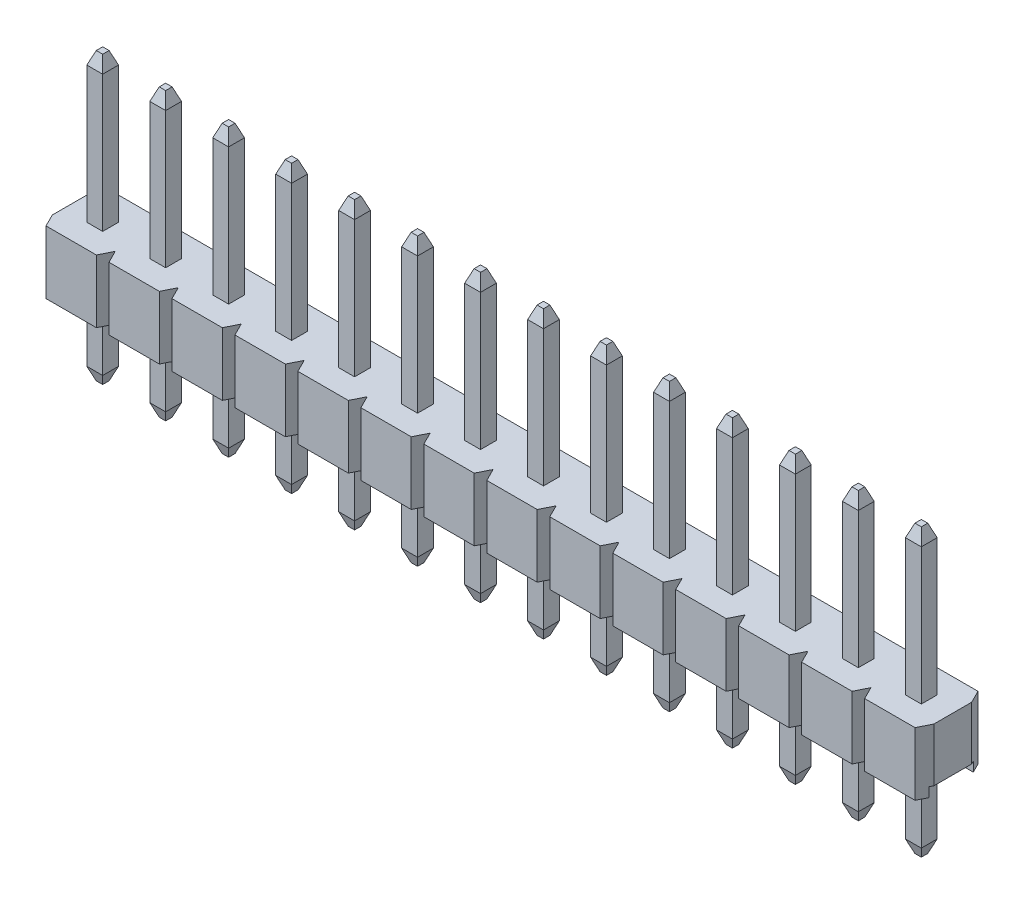
from build123d import *
from OCP.BRepFilletAPI import BRepFilletAPI_MakeChamfer

# Parameters (mm, degrees)
SKETCH1_W                     = 2.54
SKETCH1_H                     = 2.54
MAIN_BODY_DEPTH               = 2.54
SKETCH3_W                     = 1.778
SKETCH3_H                     = 0.381
CUT_EXTRUDE1_DEPTH            = 5.399409051
CUT_EXTRUDE2_DEPTH            = 5.399409051
BODY_PATTERN_COUNT            = 14
BODY_PATTERN_PITCH            = 2.54
PIN_START                     = -5.54
SKETCH2_W                     = 0.64
SKETCH2_H                     = 0.64
PIN_DEPTH                     = 11.54
CHAMFER1_SIZE                 = 0.508
CHAMFER1_SIZE2                = 0.1905
CHAMFER2_SIZE                 = 0.1905
CHAMFER2_SIZE2                = 0.508
PIN_PATTERN_COUNT             = 14
PIN_PATTERN_PITCH             = 2.54
CHAMFER1_OF_PIN_PATTERN_SIZE  = 0.508
CHAMFER1_OF_PIN_PATTERN_SIZE2 = 0.1905
CHAMFER2_OF_PIN_PATTERN_SIZE2 = 0.1905
CHAMFER2_OF_PIN_PATTERN_SIZE  = 0.508


with BuildPart() as part:
    # Sketch1 → Main Body (new body)
    with BuildSketch(Plane(origin=(0, 0, 0), x_dir=(1, 0, 0), z_dir=(0, 1, 0))):
        with Locations((1.27, 1.27)):
            Rectangle(SKETCH1_W, SKETCH1_H)
    main_body = extrude(amount=MAIN_BODY_DEPTH)

    # Sketch3 → Cut-Extrude1 (cut, through all)
    with BuildSketch(Plane.ZY):
        with Locations((-1.27, 0.1905)):
            Rectangle(SKETCH3_W, SKETCH3_H)
    cut_extrude1 = extrude(amount=-CUT_EXTRUDE1_DEPTH, mode=Mode.SUBTRACT)

    # Sketch4 → Cut-Extrude2 (cut, through all)
    with BuildSketch(Plane(origin=(0, 2.54, 0), x_dir=(1, 0, 0), z_dir=(0, 1, 0))):
        Polygon((0.254, 2.54), (0, 2.54), (0, 2.032), align=None)
        Polygon((2.54, 2.54), (2.286, 2.54), (2.54, 2.032), align=None)
        Polygon((0.254, 0), (0, 0.508), (0, 0), align=None)
        Polygon((2.54, 0), (2.286, 0), (2.54, 0.508), align=None)
    cut_extrude2 = extrude(amount=-CUT_EXTRUDE2_DEPTH, mode=Mode.SUBTRACT)

    # Body Pattern: Main Body, Cut-Extrude1, Cut-Extrude2 ×14
    with Locations(*[(-i * BODY_PATTERN_PITCH, 0, 0) for i in range(1, BODY_PATTERN_COUNT)]):
        add(main_body)
        add(cut_extrude1, mode=Mode.SUBTRACT)
        add(cut_extrude2, mode=Mode.SUBTRACT)

    # Sketch2 → Pin (add)
    with BuildSketch(Plane(origin=(0, 2.54, 0), x_dir=(1, 0, 0), z_dir=(0, 1, 0)).offset(PIN_START)):
        with Locations((1.27, 1.27)):
            Rectangle(SKETCH2_W, SKETCH2_H)
    pin = extrude(amount=PIN_DEPTH)

    # Chamfer1: one chamfer whose edges measure the first distance from different faces: ONE call of the kernel's chamfer builder (chamfer() names one face for all edges)
    chamfer1_edges_1 = [part.edges().sort_by_distance(p)[0] for p in [
        (0.95, 8.54, -1.27),
    ]]
    chamfer1_side_1 = [part.faces().sort_by_distance(p)[0] for p in [
        (0.95, 5.54, -1.27),
    ]]
    chamfer1_edges_2 = [part.edges().sort_by_distance(p)[0] for p in [
        (1.27, 8.54, -0.95),
    ]]
    chamfer1_side_2 = [part.faces().sort_by_distance(p)[0] for p in [
        (1.27, 5.54, -0.95),
    ]]
    chamfer1_edges_3 = [part.edges().sort_by_distance(p)[0] for p in [
        (1.59, 8.54, -1.27),
    ]]
    chamfer1_side_3 = [part.faces().sort_by_distance(p)[0] for p in [
        (1.59, 5.54, -1.27),
    ]]
    chamfer1_edges_4 = [part.edges().sort_by_distance(p)[0] for p in [
        (1.27, 8.54, -1.59),
    ]]
    chamfer1_side_4 = [part.faces().sort_by_distance(p)[0] for p in [
        (1.27, 5.54, -1.59),
    ]]
    chamfer1 = BRepFilletAPI_MakeChamfer(part.part.solid().wrapped)
    for e in chamfer1_edges_1:
        chamfer1.Add(CHAMFER1_SIZE, CHAMFER1_SIZE2, e.wrapped, chamfer1_side_1[0].wrapped)  # the first distance lies on this face
    for e in chamfer1_edges_2:
        chamfer1.Add(CHAMFER1_SIZE, CHAMFER1_SIZE2, e.wrapped, chamfer1_side_2[0].wrapped)  # the first distance lies on this face
    for e in chamfer1_edges_3:
        chamfer1.Add(CHAMFER1_SIZE, CHAMFER1_SIZE2, e.wrapped, chamfer1_side_3[0].wrapped)  # the first distance lies on this face
    for e in chamfer1_edges_4:
        chamfer1.Add(CHAMFER1_SIZE, CHAMFER1_SIZE2, e.wrapped, chamfer1_side_4[0].wrapped)  # the first distance lies on this face
    add(Compound.cast(chamfer1.Shape()), mode=Mode.REPLACE)

    # Chamfer2
    chamfer2_edges = [part.edges().sort_by_distance(p)[0] for p in [
        (1.27, -3, -0.95),
        (1.59, -3, -1.27),
        (1.27, -3, -1.59),
        (0.95, -3, -1.27),
    ]]
    chamfer2_side = [part.faces().sort_by_distance(p)[0] for p in [
        (1.27, -3, -1.27),
    ]]
    chamfer(chamfer2_edges, length=CHAMFER2_SIZE, length2=CHAMFER2_SIZE2, reference=chamfer2_side[0])

    # Pin Pattern: Pin ×14
    with Locations(*[(-i * PIN_PATTERN_PITCH, 0, 0) for i in range(1, PIN_PATTERN_COUNT)]):
        add(pin)

    # Chamfer1 of Pin Pattern: one chamfer whose edges measure the first distance from different faces: ONE call of the kernel's chamfer builder (chamfer() names one face for all edges)
    chamfer1_of_pin_pattern_edges_1 = [part.edges().sort_by_distance(p)[0] for p in [
        (-1.59, 8.54, -1.27),
    ]]
    chamfer1_of_pin_pattern_side_1 = [part.faces().sort_by_distance(p)[0] for p in [
        (-1.59, 5.54, -1.27),
    ]]
    chamfer1_of_pin_pattern_edges_2 = [part.edges().sort_by_distance(p)[0] for p in [
        (-1.27, 8.54, -0.95),
    ]]
    chamfer1_of_pin_pattern_side_2 = [part.faces().sort_by_distance(p)[0] for p in [
        (-1.27, 5.54, -0.95),
    ]]
    chamfer1_of_pin_pattern_edges_3 = [part.edges().sort_by_distance(p)[0] for p in [
        (-0.95, 8.54, -1.27),
    ]]
    chamfer1_of_pin_pattern_side_3 = [part.faces().sort_by_distance(p)[0] for p in [
        (-0.95, 5.54, -1.27),
    ]]
    chamfer1_of_pin_pattern_edges_4 = [part.edges().sort_by_distance(p)[0] for p in [
        (-1.27, 8.54, -1.59),
    ]]
    chamfer1_of_pin_pattern_side_4 = [part.faces().sort_by_distance(p)[0] for p in [
        (-1.27, 5.54, -1.59),
    ]]
    chamfer1_of_pin_pattern_edges_5 = [part.edges().sort_by_distance(p)[0] for p in [
        (-4.13, 8.54, -1.27),
    ]]
    chamfer1_of_pin_pattern_side_5 = [part.faces().sort_by_distance(p)[0] for p in [
        (-4.13, 5.54, -1.27),
    ]]
    chamfer1_of_pin_pattern_edges_6 = [part.edges().sort_by_distance(p)[0] for p in [
        (-3.81, 8.54, -0.95),
    ]]
    chamfer1_of_pin_pattern_side_6 = [part.faces().sort_by_distance(p)[0] for p in [
        (-3.81, 5.54, -0.95),
    ]]
    chamfer1_of_pin_pattern_edges_7 = [part.edges().sort_by_distance(p)[0] for p in [
        (-3.49, 8.54, -1.27),
    ]]
    chamfer1_of_pin_pattern_side_7 = [part.faces().sort_by_distance(p)[0] for p in [
        (-3.49, 5.54, -1.27),
    ]]
    chamfer1_of_pin_pattern_edges_8 = [part.edges().sort_by_distance(p)[0] for p in [
        (-3.81, 8.54, -1.59),
    ]]
    chamfer1_of_pin_pattern_side_8 = [part.faces().sort_by_distance(p)[0] for p in [
        (-3.81, 5.54, -1.59),
    ]]
    chamfer1_of_pin_pattern_edges_9 = [part.edges().sort_by_distance(p)[0] for p in [
        (-6.67, 8.54, -1.27),
    ]]
    chamfer1_of_pin_pattern_side_9 = [part.faces().sort_by_distance(p)[0] for p in [
        (-6.67, 5.54, -1.27),
    ]]
    chamfer1_of_pin_pattern_edges_10 = [part.edges().sort_by_distance(p)[0] for p in [
        (-6.35, 8.54, -0.95),
    ]]
    chamfer1_of_pin_pattern_side_10 = [part.faces().sort_by_distance(p)[0] for p in [
        (-6.35, 5.54, -0.95),
    ]]
    chamfer1_of_pin_pattern_edges_11 = [part.edges().sort_by_distance(p)[0] for p in [
        (-6.03, 8.54, -1.27),
    ]]
    chamfer1_of_pin_pattern_side_11 = [part.faces().sort_by_distance(p)[0] for p in [
        (-6.03, 5.54, -1.27),
    ]]
    chamfer1_of_pin_pattern_edges_12 = [part.edges().sort_by_distance(p)[0] for p in [
        (-6.35, 8.54, -1.59),
    ]]
    chamfer1_of_pin_pattern_side_12 = [part.faces().sort_by_distance(p)[0] for p in [
        (-6.35, 5.54, -1.59),
    ]]
    chamfer1_of_pin_pattern_edges_13 = [part.edges().sort_by_distance(p)[0] for p in [
        (-9.21, 8.54, -1.27),
    ]]
    chamfer1_of_pin_pattern_side_13 = [part.faces().sort_by_distance(p)[0] for p in [
        (-9.21, 5.54, -1.27),
    ]]
    chamfer1_of_pin_pattern_edges_14 = [part.edges().sort_by_distance(p)[0] for p in [
        (-8.89, 8.54, -0.95),
    ]]
    chamfer1_of_pin_pattern_side_14 = [part.faces().sort_by_distance(p)[0] for p in [
        (-8.89, 5.54, -0.95),
    ]]
    chamfer1_of_pin_pattern_edges_15 = [part.edges().sort_by_distance(p)[0] for p in [
        (-8.57, 8.54, -1.27),
    ]]
    chamfer1_of_pin_pattern_side_15 = [part.faces().sort_by_distance(p)[0] for p in [
        (-8.57, 5.54, -1.27),
    ]]
    chamfer1_of_pin_pattern_edges_16 = [part.edges().sort_by_distance(p)[0] for p in [
        (-8.89, 8.54, -1.59),
    ]]
    chamfer1_of_pin_pattern_side_16 = [part.faces().sort_by_distance(p)[0] for p in [
        (-8.89, 5.54, -1.59),
    ]]
    chamfer1_of_pin_pattern_edges_17 = [part.edges().sort_by_distance(p)[0] for p in [
        (-11.75, 8.54, -1.27),
    ]]
    chamfer1_of_pin_pattern_side_17 = [part.faces().sort_by_distance(p)[0] for p in [
        (-11.75, 5.54, -1.27),
    ]]
    chamfer1_of_pin_pattern_edges_18 = [part.edges().sort_by_distance(p)[0] for p in [
        (-11.43, 8.54, -0.95),
    ]]
    chamfer1_of_pin_pattern_side_18 = [part.faces().sort_by_distance(p)[0] for p in [
        (-11.43, 5.54, -0.95),
    ]]
    chamfer1_of_pin_pattern_edges_19 = [part.edges().sort_by_distance(p)[0] for p in [
        (-11.11, 8.54, -1.27),
    ]]
    chamfer1_of_pin_pattern_side_19 = [part.faces().sort_by_distance(p)[0] for p in [
        (-11.11, 5.54, -1.27),
    ]]
    chamfer1_of_pin_pattern_edges_20 = [part.edges().sort_by_distance(p)[0] for p in [
        (-11.43, 8.54, -1.59),
    ]]
    chamfer1_of_pin_pattern_side_20 = [part.faces().sort_by_distance(p)[0] for p in [
        (-11.43, 5.54, -1.59),
    ]]
    chamfer1_of_pin_pattern_edges_21 = [part.edges().sort_by_distance(p)[0] for p in [
        (-14.29, 8.54, -1.27),
    ]]
    chamfer1_of_pin_pattern_side_21 = [part.faces().sort_by_distance(p)[0] for p in [
        (-14.29, 5.54, -1.27),
    ]]
    chamfer1_of_pin_pattern_edges_22 = [part.edges().sort_by_distance(p)[0] for p in [
        (-13.97, 8.54, -0.95),
    ]]
    chamfer1_of_pin_pattern_side_22 = [part.faces().sort_by_distance(p)[0] for p in [
        (-13.97, 5.54, -0.95),
    ]]
    chamfer1_of_pin_pattern_edges_23 = [part.edges().sort_by_distance(p)[0] for p in [
        (-13.65, 8.54, -1.27),
    ]]
    chamfer1_of_pin_pattern_side_23 = [part.faces().sort_by_distance(p)[0] for p in [
        (-13.65, 5.54, -1.27),
    ]]
    chamfer1_of_pin_pattern_edges_24 = [part.edges().sort_by_distance(p)[0] for p in [
        (-13.97, 8.54, -1.59),
    ]]
    chamfer1_of_pin_pattern_side_24 = [part.faces().sort_by_distance(p)[0] for p in [
        (-13.97, 5.54, -1.59),
    ]]
    chamfer1_of_pin_pattern_edges_25 = [part.edges().sort_by_distance(p)[0] for p in [
        (-16.83, 8.54, -1.27),
    ]]
    chamfer1_of_pin_pattern_side_25 = [part.faces().sort_by_distance(p)[0] for p in [
        (-16.83, 5.54, -1.27),
    ]]
    chamfer1_of_pin_pattern_edges_26 = [part.edges().sort_by_distance(p)[0] for p in [
        (-16.51, 8.54, -0.95),
    ]]
    chamfer1_of_pin_pattern_side_26 = [part.faces().sort_by_distance(p)[0] for p in [
        (-16.51, 5.54, -0.95),
    ]]
    chamfer1_of_pin_pattern_edges_27 = [part.edges().sort_by_distance(p)[0] for p in [
        (-16.19, 8.54, -1.27),
    ]]
    chamfer1_of_pin_pattern_side_27 = [part.faces().sort_by_distance(p)[0] for p in [
        (-16.19, 5.54, -1.27),
    ]]
    chamfer1_of_pin_pattern_edges_28 = [part.edges().sort_by_distance(p)[0] for p in [
        (-16.51, 8.54, -1.59),
    ]]
    chamfer1_of_pin_pattern_side_28 = [part.faces().sort_by_distance(p)[0] for p in [
        (-16.51, 5.54, -1.59),
    ]]
    chamfer1_of_pin_pattern_edges_29 = [part.edges().sort_by_distance(p)[0] for p in [
        (-19.37, 8.54, -1.27),
    ]]
    chamfer1_of_pin_pattern_side_29 = [part.faces().sort_by_distance(p)[0] for p in [
        (-19.37, 5.54, -1.27),
    ]]
    chamfer1_of_pin_pattern_edges_30 = [part.edges().sort_by_distance(p)[0] for p in [
        (-19.05, 8.54, -0.95),
    ]]
    chamfer1_of_pin_pattern_side_30 = [part.faces().sort_by_distance(p)[0] for p in [
        (-19.05, 5.54, -0.95),
    ]]
    chamfer1_of_pin_pattern_edges_31 = [part.edges().sort_by_distance(p)[0] for p in [
        (-18.73, 8.54, -1.27),
    ]]
    chamfer1_of_pin_pattern_side_31 = [part.faces().sort_by_distance(p)[0] for p in [
        (-18.73, 5.54, -1.27),
    ]]
    chamfer1_of_pin_pattern_edges_32 = [part.edges().sort_by_distance(p)[0] for p in [
        (-19.05, 8.54, -1.59),
    ]]
    chamfer1_of_pin_pattern_side_32 = [part.faces().sort_by_distance(p)[0] for p in [
        (-19.05, 5.54, -1.59),
    ]]
    chamfer1_of_pin_pattern_edges_33 = [part.edges().sort_by_distance(p)[0] for p in [
        (-21.91, 8.54, -1.27),
    ]]
    chamfer1_of_pin_pattern_side_33 = [part.faces().sort_by_distance(p)[0] for p in [
        (-21.91, 5.54, -1.27),
    ]]
    chamfer1_of_pin_pattern_edges_34 = [part.edges().sort_by_distance(p)[0] for p in [
        (-21.59, 8.54, -0.95),
    ]]
    chamfer1_of_pin_pattern_side_34 = [part.faces().sort_by_distance(p)[0] for p in [
        (-21.59, 5.54, -0.95),
    ]]
    chamfer1_of_pin_pattern_edges_35 = [part.edges().sort_by_distance(p)[0] for p in [
        (-21.27, 8.54, -1.27),
    ]]
    chamfer1_of_pin_pattern_side_35 = [part.faces().sort_by_distance(p)[0] for p in [
        (-21.27, 5.54, -1.27),
    ]]
    chamfer1_of_pin_pattern_edges_36 = [part.edges().sort_by_distance(p)[0] for p in [
        (-21.59, 8.54, -1.59),
    ]]
    chamfer1_of_pin_pattern_side_36 = [part.faces().sort_by_distance(p)[0] for p in [
        (-21.59, 5.54, -1.59),
    ]]
    chamfer1_of_pin_pattern_edges_37 = [part.edges().sort_by_distance(p)[0] for p in [
        (-24.45, 8.54, -1.27),
    ]]
    chamfer1_of_pin_pattern_side_37 = [part.faces().sort_by_distance(p)[0] for p in [
        (-24.45, 5.54, -1.27),
    ]]
    chamfer1_of_pin_pattern_edges_38 = [part.edges().sort_by_distance(p)[0] for p in [
        (-24.13, 8.54, -0.95),
    ]]
    chamfer1_of_pin_pattern_side_38 = [part.faces().sort_by_distance(p)[0] for p in [
        (-24.13, 5.54, -0.95),
    ]]
    chamfer1_of_pin_pattern_edges_39 = [part.edges().sort_by_distance(p)[0] for p in [
        (-23.81, 8.54, -1.27),
    ]]
    chamfer1_of_pin_pattern_side_39 = [part.faces().sort_by_distance(p)[0] for p in [
        (-23.81, 5.54, -1.27),
    ]]
    chamfer1_of_pin_pattern_edges_40 = [part.edges().sort_by_distance(p)[0] for p in [
        (-24.13, 8.54, -1.59),
    ]]
    chamfer1_of_pin_pattern_side_40 = [part.faces().sort_by_distance(p)[0] for p in [
        (-24.13, 5.54, -1.59),
    ]]
    chamfer1_of_pin_pattern_edges_41 = [part.edges().sort_by_distance(p)[0] for p in [
        (-26.99, 8.54, -1.27),
    ]]
    chamfer1_of_pin_pattern_side_41 = [part.faces().sort_by_distance(p)[0] for p in [
        (-26.99, 5.54, -1.27),
    ]]
    chamfer1_of_pin_pattern_edges_42 = [part.edges().sort_by_distance(p)[0] for p in [
        (-26.67, 8.54, -0.95),
    ]]
    chamfer1_of_pin_pattern_side_42 = [part.faces().sort_by_distance(p)[0] for p in [
        (-26.67, 5.54, -0.95),
    ]]
    chamfer1_of_pin_pattern_edges_43 = [part.edges().sort_by_distance(p)[0] for p in [
        (-26.35, 8.54, -1.27),
    ]]
    chamfer1_of_pin_pattern_side_43 = [part.faces().sort_by_distance(p)[0] for p in [
        (-26.35, 5.54, -1.27),
    ]]
    chamfer1_of_pin_pattern_edges_44 = [part.edges().sort_by_distance(p)[0] for p in [
        (-26.67, 8.54, -1.59),
    ]]
    chamfer1_of_pin_pattern_side_44 = [part.faces().sort_by_distance(p)[0] for p in [
        (-26.67, 5.54, -1.59),
    ]]
    chamfer1_of_pin_pattern_edges_45 = [part.edges().sort_by_distance(p)[0] for p in [
        (-29.53, 8.54, -1.27),
    ]]
    chamfer1_of_pin_pattern_side_45 = [part.faces().sort_by_distance(p)[0] for p in [
        (-29.53, 5.54, -1.27),
    ]]
    chamfer1_of_pin_pattern_edges_46 = [part.edges().sort_by_distance(p)[0] for p in [
        (-29.21, 8.54, -0.95),
    ]]
    chamfer1_of_pin_pattern_side_46 = [part.faces().sort_by_distance(p)[0] for p in [
        (-29.21, 5.54, -0.95),
    ]]
    chamfer1_of_pin_pattern_edges_47 = [part.edges().sort_by_distance(p)[0] for p in [
        (-28.89, 8.54, -1.27),
    ]]
    chamfer1_of_pin_pattern_side_47 = [part.faces().sort_by_distance(p)[0] for p in [
        (-28.89, 5.54, -1.27),
    ]]
    chamfer1_of_pin_pattern_edges_48 = [part.edges().sort_by_distance(p)[0] for p in [
        (-29.21, 8.54, -1.59),
    ]]
    chamfer1_of_pin_pattern_side_48 = [part.faces().sort_by_distance(p)[0] for p in [
        (-29.21, 5.54, -1.59),
    ]]
    chamfer1_of_pin_pattern_edges_49 = [part.edges().sort_by_distance(p)[0] for p in [
        (-32.07, 8.54, -1.27),
    ]]
    chamfer1_of_pin_pattern_side_49 = [part.faces().sort_by_distance(p)[0] for p in [
        (-32.07, 5.54, -1.27),
    ]]
    chamfer1_of_pin_pattern_edges_50 = [part.edges().sort_by_distance(p)[0] for p in [
        (-31.75, 8.54, -0.95),
    ]]
    chamfer1_of_pin_pattern_side_50 = [part.faces().sort_by_distance(p)[0] for p in [
        (-31.75, 5.54, -0.95),
    ]]
    chamfer1_of_pin_pattern_edges_51 = [part.edges().sort_by_distance(p)[0] for p in [
        (-31.43, 8.54, -1.27),
    ]]
    chamfer1_of_pin_pattern_side_51 = [part.faces().sort_by_distance(p)[0] for p in [
        (-31.43, 5.54, -1.27),
    ]]
    chamfer1_of_pin_pattern_edges_52 = [part.edges().sort_by_distance(p)[0] for p in [
        (-31.75, 8.54, -1.59),
    ]]
    chamfer1_of_pin_pattern_side_52 = [part.faces().sort_by_distance(p)[0] for p in [
        (-31.75, 5.54, -1.59),
    ]]
    chamfer1_of_pin_pattern = BRepFilletAPI_MakeChamfer(part.part.solid().wrapped)
    for e in chamfer1_of_pin_pattern_edges_1:
        chamfer1_of_pin_pattern.Add(CHAMFER1_OF_PIN_PATTERN_SIZE, CHAMFER1_OF_PIN_PATTERN_SIZE2, e.wrapped, chamfer1_of_pin_pattern_side_1[0].wrapped)  # the first distance lies on this face
    for e in chamfer1_of_pin_pattern_edges_2:
        chamfer1_of_pin_pattern.Add(CHAMFER1_OF_PIN_PATTERN_SIZE, CHAMFER1_OF_PIN_PATTERN_SIZE2, e.wrapped, chamfer1_of_pin_pattern_side_2[0].wrapped)  # the first distance lies on this face
    for e in chamfer1_of_pin_pattern_edges_3:
        chamfer1_of_pin_pattern.Add(CHAMFER1_OF_PIN_PATTERN_SIZE, CHAMFER1_OF_PIN_PATTERN_SIZE2, e.wrapped, chamfer1_of_pin_pattern_side_3[0].wrapped)  # the first distance lies on this face
    for e in chamfer1_of_pin_pattern_edges_4:
        chamfer1_of_pin_pattern.Add(CHAMFER1_OF_PIN_PATTERN_SIZE, CHAMFER1_OF_PIN_PATTERN_SIZE2, e.wrapped, chamfer1_of_pin_pattern_side_4[0].wrapped)  # the first distance lies on this face
    for e in chamfer1_of_pin_pattern_edges_5:
        chamfer1_of_pin_pattern.Add(CHAMFER1_OF_PIN_PATTERN_SIZE, CHAMFER1_OF_PIN_PATTERN_SIZE2, e.wrapped, chamfer1_of_pin_pattern_side_5[0].wrapped)  # the first distance lies on this face
    for e in chamfer1_of_pin_pattern_edges_6:
        chamfer1_of_pin_pattern.Add(CHAMFER1_OF_PIN_PATTERN_SIZE, CHAMFER1_OF_PIN_PATTERN_SIZE2, e.wrapped, chamfer1_of_pin_pattern_side_6[0].wrapped)  # the first distance lies on this face
    for e in chamfer1_of_pin_pattern_edges_7:
        chamfer1_of_pin_pattern.Add(CHAMFER1_OF_PIN_PATTERN_SIZE, CHAMFER1_OF_PIN_PATTERN_SIZE2, e.wrapped, chamfer1_of_pin_pattern_side_7[0].wrapped)  # the first distance lies on this face
    for e in chamfer1_of_pin_pattern_edges_8:
        chamfer1_of_pin_pattern.Add(CHAMFER1_OF_PIN_PATTERN_SIZE, CHAMFER1_OF_PIN_PATTERN_SIZE2, e.wrapped, chamfer1_of_pin_pattern_side_8[0].wrapped)  # the first distance lies on this face
    for e in chamfer1_of_pin_pattern_edges_9:
        chamfer1_of_pin_pattern.Add(CHAMFER1_OF_PIN_PATTERN_SIZE, CHAMFER1_OF_PIN_PATTERN_SIZE2, e.wrapped, chamfer1_of_pin_pattern_side_9[0].wrapped)  # the first distance lies on this face
    for e in chamfer1_of_pin_pattern_edges_10:
        chamfer1_of_pin_pattern.Add(CHAMFER1_OF_PIN_PATTERN_SIZE, CHAMFER1_OF_PIN_PATTERN_SIZE2, e.wrapped, chamfer1_of_pin_pattern_side_10[0].wrapped)  # the first distance lies on this face
    for e in chamfer1_of_pin_pattern_edges_11:
        chamfer1_of_pin_pattern.Add(CHAMFER1_OF_PIN_PATTERN_SIZE, CHAMFER1_OF_PIN_PATTERN_SIZE2, e.wrapped, chamfer1_of_pin_pattern_side_11[0].wrapped)  # the first distance lies on this face
    for e in chamfer1_of_pin_pattern_edges_12:
        chamfer1_of_pin_pattern.Add(CHAMFER1_OF_PIN_PATTERN_SIZE, CHAMFER1_OF_PIN_PATTERN_SIZE2, e.wrapped, chamfer1_of_pin_pattern_side_12[0].wrapped)  # the first distance lies on this face
    for e in chamfer1_of_pin_pattern_edges_13:
        chamfer1_of_pin_pattern.Add(CHAMFER1_OF_PIN_PATTERN_SIZE, CHAMFER1_OF_PIN_PATTERN_SIZE2, e.wrapped, chamfer1_of_pin_pattern_side_13[0].wrapped)  # the first distance lies on this face
    for e in chamfer1_of_pin_pattern_edges_14:
        chamfer1_of_pin_pattern.Add(CHAMFER1_OF_PIN_PATTERN_SIZE, CHAMFER1_OF_PIN_PATTERN_SIZE2, e.wrapped, chamfer1_of_pin_pattern_side_14[0].wrapped)  # the first distance lies on this face
    for e in chamfer1_of_pin_pattern_edges_15:
        chamfer1_of_pin_pattern.Add(CHAMFER1_OF_PIN_PATTERN_SIZE, CHAMFER1_OF_PIN_PATTERN_SIZE2, e.wrapped, chamfer1_of_pin_pattern_side_15[0].wrapped)  # the first distance lies on this face
    for e in chamfer1_of_pin_pattern_edges_16:
        chamfer1_of_pin_pattern.Add(CHAMFER1_OF_PIN_PATTERN_SIZE, CHAMFER1_OF_PIN_PATTERN_SIZE2, e.wrapped, chamfer1_of_pin_pattern_side_16[0].wrapped)  # the first distance lies on this face
    for e in chamfer1_of_pin_pattern_edges_17:
        chamfer1_of_pin_pattern.Add(CHAMFER1_OF_PIN_PATTERN_SIZE, CHAMFER1_OF_PIN_PATTERN_SIZE2, e.wrapped, chamfer1_of_pin_pattern_side_17[0].wrapped)  # the first distance lies on this face
    for e in chamfer1_of_pin_pattern_edges_18:
        chamfer1_of_pin_pattern.Add(CHAMFER1_OF_PIN_PATTERN_SIZE, CHAMFER1_OF_PIN_PATTERN_SIZE2, e.wrapped, chamfer1_of_pin_pattern_side_18[0].wrapped)  # the first distance lies on this face
    for e in chamfer1_of_pin_pattern_edges_19:
        chamfer1_of_pin_pattern.Add(CHAMFER1_OF_PIN_PATTERN_SIZE, CHAMFER1_OF_PIN_PATTERN_SIZE2, e.wrapped, chamfer1_of_pin_pattern_side_19[0].wrapped)  # the first distance lies on this face
    for e in chamfer1_of_pin_pattern_edges_20:
        chamfer1_of_pin_pattern.Add(CHAMFER1_OF_PIN_PATTERN_SIZE, CHAMFER1_OF_PIN_PATTERN_SIZE2, e.wrapped, chamfer1_of_pin_pattern_side_20[0].wrapped)  # the first distance lies on this face
    for e in chamfer1_of_pin_pattern_edges_21:
        chamfer1_of_pin_pattern.Add(CHAMFER1_OF_PIN_PATTERN_SIZE, CHAMFER1_OF_PIN_PATTERN_SIZE2, e.wrapped, chamfer1_of_pin_pattern_side_21[0].wrapped)  # the first distance lies on this face
    for e in chamfer1_of_pin_pattern_edges_22:
        chamfer1_of_pin_pattern.Add(CHAMFER1_OF_PIN_PATTERN_SIZE, CHAMFER1_OF_PIN_PATTERN_SIZE2, e.wrapped, chamfer1_of_pin_pattern_side_22[0].wrapped)  # the first distance lies on this face
    for e in chamfer1_of_pin_pattern_edges_23:
        chamfer1_of_pin_pattern.Add(CHAMFER1_OF_PIN_PATTERN_SIZE, CHAMFER1_OF_PIN_PATTERN_SIZE2, e.wrapped, chamfer1_of_pin_pattern_side_23[0].wrapped)  # the first distance lies on this face
    for e in chamfer1_of_pin_pattern_edges_24:
        chamfer1_of_pin_pattern.Add(CHAMFER1_OF_PIN_PATTERN_SIZE, CHAMFER1_OF_PIN_PATTERN_SIZE2, e.wrapped, chamfer1_of_pin_pattern_side_24[0].wrapped)  # the first distance lies on this face
    for e in chamfer1_of_pin_pattern_edges_25:
        chamfer1_of_pin_pattern.Add(CHAMFER1_OF_PIN_PATTERN_SIZE, CHAMFER1_OF_PIN_PATTERN_SIZE2, e.wrapped, chamfer1_of_pin_pattern_side_25[0].wrapped)  # the first distance lies on this face
    for e in chamfer1_of_pin_pattern_edges_26:
        chamfer1_of_pin_pattern.Add(CHAMFER1_OF_PIN_PATTERN_SIZE, CHAMFER1_OF_PIN_PATTERN_SIZE2, e.wrapped, chamfer1_of_pin_pattern_side_26[0].wrapped)  # the first distance lies on this face
    for e in chamfer1_of_pin_pattern_edges_27:
        chamfer1_of_pin_pattern.Add(CHAMFER1_OF_PIN_PATTERN_SIZE, CHAMFER1_OF_PIN_PATTERN_SIZE2, e.wrapped, chamfer1_of_pin_pattern_side_27[0].wrapped)  # the first distance lies on this face
    for e in chamfer1_of_pin_pattern_edges_28:
        chamfer1_of_pin_pattern.Add(CHAMFER1_OF_PIN_PATTERN_SIZE, CHAMFER1_OF_PIN_PATTERN_SIZE2, e.wrapped, chamfer1_of_pin_pattern_side_28[0].wrapped)  # the first distance lies on this face
    for e in chamfer1_of_pin_pattern_edges_29:
        chamfer1_of_pin_pattern.Add(CHAMFER1_OF_PIN_PATTERN_SIZE, CHAMFER1_OF_PIN_PATTERN_SIZE2, e.wrapped, chamfer1_of_pin_pattern_side_29[0].wrapped)  # the first distance lies on this face
    for e in chamfer1_of_pin_pattern_edges_30:
        chamfer1_of_pin_pattern.Add(CHAMFER1_OF_PIN_PATTERN_SIZE, CHAMFER1_OF_PIN_PATTERN_SIZE2, e.wrapped, chamfer1_of_pin_pattern_side_30[0].wrapped)  # the first distance lies on this face
    for e in chamfer1_of_pin_pattern_edges_31:
        chamfer1_of_pin_pattern.Add(CHAMFER1_OF_PIN_PATTERN_SIZE, CHAMFER1_OF_PIN_PATTERN_SIZE2, e.wrapped, chamfer1_of_pin_pattern_side_31[0].wrapped)  # the first distance lies on this face
    for e in chamfer1_of_pin_pattern_edges_32:
        chamfer1_of_pin_pattern.Add(CHAMFER1_OF_PIN_PATTERN_SIZE, CHAMFER1_OF_PIN_PATTERN_SIZE2, e.wrapped, chamfer1_of_pin_pattern_side_32[0].wrapped)  # the first distance lies on this face
    for e in chamfer1_of_pin_pattern_edges_33:
        chamfer1_of_pin_pattern.Add(CHAMFER1_OF_PIN_PATTERN_SIZE, CHAMFER1_OF_PIN_PATTERN_SIZE2, e.wrapped, chamfer1_of_pin_pattern_side_33[0].wrapped)  # the first distance lies on this face
    for e in chamfer1_of_pin_pattern_edges_34:
        chamfer1_of_pin_pattern.Add(CHAMFER1_OF_PIN_PATTERN_SIZE, CHAMFER1_OF_PIN_PATTERN_SIZE2, e.wrapped, chamfer1_of_pin_pattern_side_34[0].wrapped)  # the first distance lies on this face
    for e in chamfer1_of_pin_pattern_edges_35:
        chamfer1_of_pin_pattern.Add(CHAMFER1_OF_PIN_PATTERN_SIZE, CHAMFER1_OF_PIN_PATTERN_SIZE2, e.wrapped, chamfer1_of_pin_pattern_side_35[0].wrapped)  # the first distance lies on this face
    for e in chamfer1_of_pin_pattern_edges_36:
        chamfer1_of_pin_pattern.Add(CHAMFER1_OF_PIN_PATTERN_SIZE, CHAMFER1_OF_PIN_PATTERN_SIZE2, e.wrapped, chamfer1_of_pin_pattern_side_36[0].wrapped)  # the first distance lies on this face
    for e in chamfer1_of_pin_pattern_edges_37:
        chamfer1_of_pin_pattern.Add(CHAMFER1_OF_PIN_PATTERN_SIZE, CHAMFER1_OF_PIN_PATTERN_SIZE2, e.wrapped, chamfer1_of_pin_pattern_side_37[0].wrapped)  # the first distance lies on this face
    for e in chamfer1_of_pin_pattern_edges_38:
        chamfer1_of_pin_pattern.Add(CHAMFER1_OF_PIN_PATTERN_SIZE, CHAMFER1_OF_PIN_PATTERN_SIZE2, e.wrapped, chamfer1_of_pin_pattern_side_38[0].wrapped)  # the first distance lies on this face
    for e in chamfer1_of_pin_pattern_edges_39:
        chamfer1_of_pin_pattern.Add(CHAMFER1_OF_PIN_PATTERN_SIZE, CHAMFER1_OF_PIN_PATTERN_SIZE2, e.wrapped, chamfer1_of_pin_pattern_side_39[0].wrapped)  # the first distance lies on this face
    for e in chamfer1_of_pin_pattern_edges_40:
        chamfer1_of_pin_pattern.Add(CHAMFER1_OF_PIN_PATTERN_SIZE, CHAMFER1_OF_PIN_PATTERN_SIZE2, e.wrapped, chamfer1_of_pin_pattern_side_40[0].wrapped)  # the first distance lies on this face
    for e in chamfer1_of_pin_pattern_edges_41:
        chamfer1_of_pin_pattern.Add(CHAMFER1_OF_PIN_PATTERN_SIZE, CHAMFER1_OF_PIN_PATTERN_SIZE2, e.wrapped, chamfer1_of_pin_pattern_side_41[0].wrapped)  # the first distance lies on this face
    for e in chamfer1_of_pin_pattern_edges_42:
        chamfer1_of_pin_pattern.Add(CHAMFER1_OF_PIN_PATTERN_SIZE, CHAMFER1_OF_PIN_PATTERN_SIZE2, e.wrapped, chamfer1_of_pin_pattern_side_42[0].wrapped)  # the first distance lies on this face
    for e in chamfer1_of_pin_pattern_edges_43:
        chamfer1_of_pin_pattern.Add(CHAMFER1_OF_PIN_PATTERN_SIZE, CHAMFER1_OF_PIN_PATTERN_SIZE2, e.wrapped, chamfer1_of_pin_pattern_side_43[0].wrapped)  # the first distance lies on this face
    for e in chamfer1_of_pin_pattern_edges_44:
        chamfer1_of_pin_pattern.Add(CHAMFER1_OF_PIN_PATTERN_SIZE, CHAMFER1_OF_PIN_PATTERN_SIZE2, e.wrapped, chamfer1_of_pin_pattern_side_44[0].wrapped)  # the first distance lies on this face
    for e in chamfer1_of_pin_pattern_edges_45:
        chamfer1_of_pin_pattern.Add(CHAMFER1_OF_PIN_PATTERN_SIZE, CHAMFER1_OF_PIN_PATTERN_SIZE2, e.wrapped, chamfer1_of_pin_pattern_side_45[0].wrapped)  # the first distance lies on this face
    for e in chamfer1_of_pin_pattern_edges_46:
        chamfer1_of_pin_pattern.Add(CHAMFER1_OF_PIN_PATTERN_SIZE, CHAMFER1_OF_PIN_PATTERN_SIZE2, e.wrapped, chamfer1_of_pin_pattern_side_46[0].wrapped)  # the first distance lies on this face
    for e in chamfer1_of_pin_pattern_edges_47:
        chamfer1_of_pin_pattern.Add(CHAMFER1_OF_PIN_PATTERN_SIZE, CHAMFER1_OF_PIN_PATTERN_SIZE2, e.wrapped, chamfer1_of_pin_pattern_side_47[0].wrapped)  # the first distance lies on this face
    for e in chamfer1_of_pin_pattern_edges_48:
        chamfer1_of_pin_pattern.Add(CHAMFER1_OF_PIN_PATTERN_SIZE, CHAMFER1_OF_PIN_PATTERN_SIZE2, e.wrapped, chamfer1_of_pin_pattern_side_48[0].wrapped)  # the first distance lies on this face
    for e in chamfer1_of_pin_pattern_edges_49:
        chamfer1_of_pin_pattern.Add(CHAMFER1_OF_PIN_PATTERN_SIZE, CHAMFER1_OF_PIN_PATTERN_SIZE2, e.wrapped, chamfer1_of_pin_pattern_side_49[0].wrapped)  # the first distance lies on this face
    for e in chamfer1_of_pin_pattern_edges_50:
        chamfer1_of_pin_pattern.Add(CHAMFER1_OF_PIN_PATTERN_SIZE, CHAMFER1_OF_PIN_PATTERN_SIZE2, e.wrapped, chamfer1_of_pin_pattern_side_50[0].wrapped)  # the first distance lies on this face
    for e in chamfer1_of_pin_pattern_edges_51:
        chamfer1_of_pin_pattern.Add(CHAMFER1_OF_PIN_PATTERN_SIZE, CHAMFER1_OF_PIN_PATTERN_SIZE2, e.wrapped, chamfer1_of_pin_pattern_side_51[0].wrapped)  # the first distance lies on this face
    for e in chamfer1_of_pin_pattern_edges_52:
        chamfer1_of_pin_pattern.Add(CHAMFER1_OF_PIN_PATTERN_SIZE, CHAMFER1_OF_PIN_PATTERN_SIZE2, e.wrapped, chamfer1_of_pin_pattern_side_52[0].wrapped)  # the first distance lies on this face
    add(Compound.cast(chamfer1_of_pin_pattern.Shape()), mode=Mode.REPLACE)

    # Chamfer2 of Pin Pattern
    chamfer2_of_pin_pattern_edges = [part.edges().sort_by_distance(p)[0] for p in [
        (-1.27, -3, -0.95),
        (-0.95, -3, -1.27),
        (-1.27, -3, -1.59),
        (-1.59, -3, -1.27),
        (-3.81, -3, -0.95),
        (-3.49, -3, -1.27),
        (-3.81, -3, -1.59),
        (-4.13, -3, -1.27),
        (-6.35, -3, -0.95),
        (-6.03, -3, -1.27),
        (-6.35, -3, -1.59),
        (-6.67, -3, -1.27),
        (-8.89, -3, -0.95),
        (-8.57, -3, -1.27),
        (-8.89, -3, -1.59),
        (-9.21, -3, -1.27),
        (-11.43, -3, -0.95),
        (-11.11, -3, -1.27),
        (-11.43, -3, -1.59),
        (-11.75, -3, -1.27),
        (-13.97, -3, -0.95),
        (-13.65, -3, -1.27),
        (-13.97, -3, -1.59),
        (-14.29, -3, -1.27),
        (-16.51, -3, -0.95),
        (-16.19, -3, -1.27),
        (-16.51, -3, -1.59),
        (-16.83, -3, -1.27),
        (-19.05, -3, -0.95),
        (-18.73, -3, -1.27),
        (-19.05, -3, -1.59),
        (-19.37, -3, -1.27),
        (-21.59, -3, -0.95),
        (-21.27, -3, -1.27),
        (-21.59, -3, -1.59),
        (-21.91, -3, -1.27),
        (-24.13, -3, -0.95),
        (-23.81, -3, -1.27),
        (-24.13, -3, -1.59),
        (-24.45, -3, -1.27),
        (-26.67, -3, -0.95),
        (-26.35, -3, -1.27),
        (-26.67, -3, -1.59),
        (-26.99, -3, -1.27),
        (-29.21, -3, -0.95),
        (-28.89, -3, -1.27),
        (-29.21, -3, -1.59),
        (-29.53, -3, -1.27),
        (-31.75, -3, -0.95),
        (-31.43, -3, -1.27),
        (-31.75, -3, -1.59),
        (-32.07, -3, -1.27),
    ]]
    chamfer(chamfer2_of_pin_pattern_edges, length=CHAMFER2_OF_PIN_PATTERN_SIZE, length2=CHAMFER2_OF_PIN_PATTERN_SIZE2)


solid = part.part
